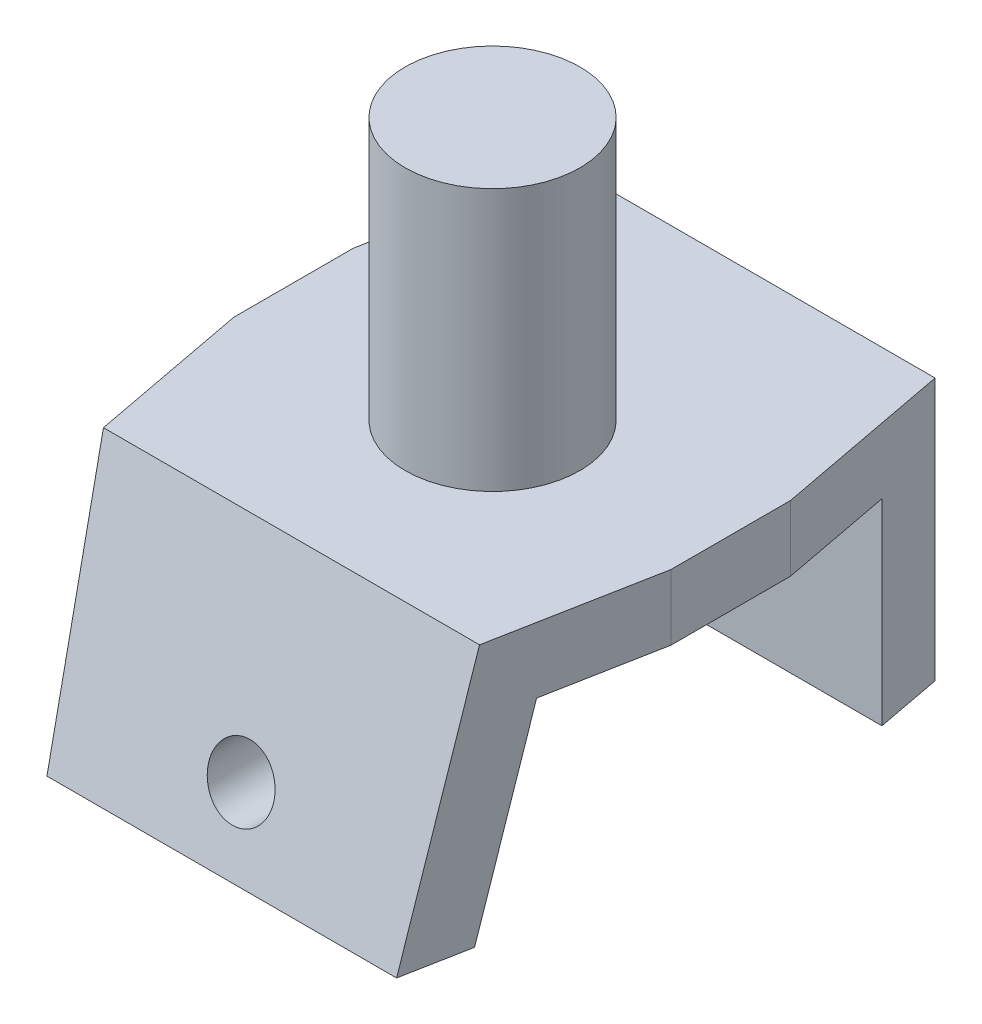
from build123d import *

# Parameters (mm, degrees)
BOSS_EXTRUDE1_DEPTH = 100
SKETCH2_R           = 7.5
CUT_EXTRUDE1_DEPTH  = 120
CUT_EXTRUDE2_DEPTH  = 100
SKETCH4_R           = 20
BOSS_EXTRUDE2_DEPTH = 60


with BuildPart() as part:
    # Sketch1 → Boss-Extrude1 (new body)
    with BuildSketch(Plane(origin=(0, 0, 0), x_dir=(0, 0, -1), z_dir=(1, 0, 0))):
        Polygon((-51.437881439, -28.738448854), (-39.5, 15.81433121), (39.5, 15.81433121), (39.5, -29.18566879), (54.5, -29.18566879), (54.5, 30.81433121), (-50.480762114, 30.81433121), (-66.437881439, -28.738448854), align=None)
    extrude(amount=BOSS_EXTRUDE1_DEPTH)

    # Sketch2 → Cut-Extrude1 (cut)
    with BuildSketch(Plane(origin=(0, 0, -54.5), x_dir=(-1, 0, 0), z_dir=(0, 0, -1))):
        with Locations((-50, -12.18566879)):
            Circle(SKETCH2_R)
    extrude(amount=-CUT_EXTRUDE1_DEPTH, mode=Mode.SUBTRACT)

    # Sketch3 → Cut-Extrude2 (cut)
    with BuildSketch(Plane(origin=(0, 30.81433121, 0), x_dir=(1, 0, 0), z_dir=(0, 1, 0))):
        Polygon((10, -66.437881439), (0, -13.684030484), (-18.365032474, -13.684030484), (-18.365032474, -72.107787752), align=None)
        Polygon((-18.365032474, 72.107787752), (10, 66.437881439), (0, 13.684030484), (-18.365032474, 13.684030484), align=None)
        Polygon((90, 66.437881439), (100, 13.684030484), (118.365032474, 13.684030484), (118.365032474, 72.107787752), align=None)
        Polygon((118.365032474, -72.107787752), (90, -66.437881439), (100, -13.684030484), (118.365032474, -13.684030484), align=None)
    extrude(amount=-CUT_EXTRUDE2_DEPTH, mode=Mode.SUBTRACT)

    # Sketch4 → Boss-Extrude2 (add)
    with BuildSketch(Plane(origin=(0, 30.81433121, 0), x_dir=(1, 0, 0), z_dir=(0, 1, 0))):
        with Locations((50, -4.480762114)):
            Circle(SKETCH4_R)
    extrude(amount=BOSS_EXTRUDE2_DEPTH)


solid = part.part
